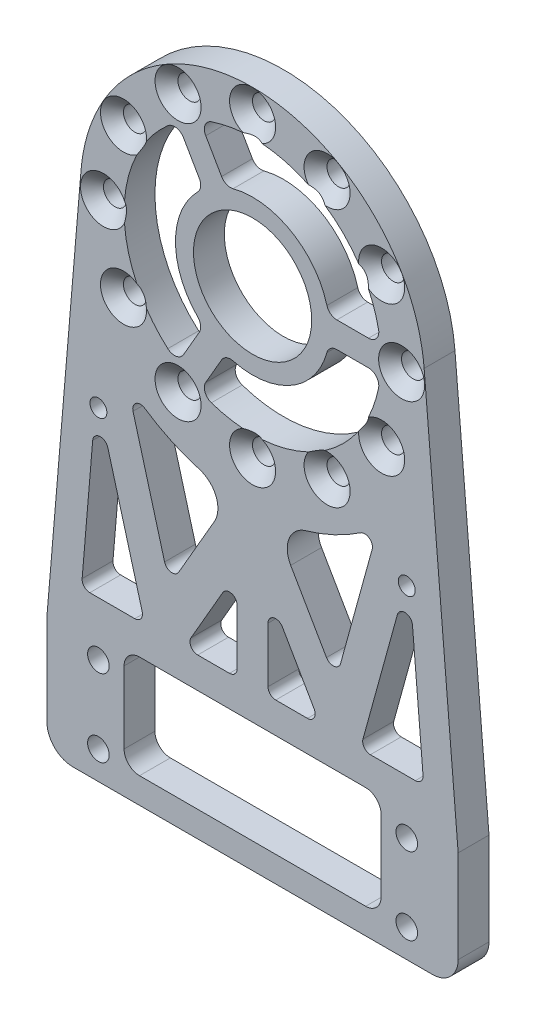
from build123d import *

# Parameters (mm, degrees)
SKETCH_1_R                   = 33.5
SKETCH_1_R_2                 = 25
SKETCH_1_W                   = 80
SKETCH_1_H                   = 20
SKETCH_1_R_3                 = 2.1
EXTRUDE_1_DEPTH              = 6
SKETCH_3_R                   = 2.05
CUT_EXTRUDE_1_DEPTH          = 7
EXTRUDE_2_DEPTH              = 6
FILLET_1_R                   = 2
SKETCH_5_W                   = 80
SKETCH_5_H                   = 3
EXTRUDE_3_DEPTH              = 6
FILLET_2_R                   = 5
SKETCH_6_W                   = 50
SKETCH_6_H                   = 20
CUT_EXTRUDE_2_DEPTH          = 10
FILLET_3_R                   = 3
FILLET_4_R                   = 1.5
FILLET_5_R                   = 5
HOLE_WIZARD_M4_2_D           = 4.5
HOLE_WIZARD_M4_2_CSINK_D     = 8.96
HOLE_WIZARD_M4_2_CSINK_ANGLE = 90
SKETCH_10_R                  = 1.65
CUT_EXTRUDE_3_DEPTH          = 7.0000001


with BuildPart() as part:
    # 草图1 → 凸台-拉伸1 (new body)
    with BuildSketch(Plane.XY):
        with Locations((0, 85.5)):
            Circle(SKETCH_1_R)
        with Locations((0, 85.5)):
            Circle(SKETCH_1_R_2, mode=Mode.SUBTRACT)
        with BuildLine():
            Line((-33.38100662, 88.32106311), (-40, 10))
            Line((-40, 10), (40, 10))
            Line((40, 10), (33.38100662, 88.32106311))
            ThreePointArc((33.38100662, 88.32106311), (33.470238435, 86.911785792), (33.5, 85.5))
            ThreePointArc((33.5, 85.5), (-1.411785792, 52.029761565), (-33.38100662, 88.32106311))
        make_face()
        Rectangle(SKETCH_1_W, SKETCH_1_H)
        with Locations((-30, 7.5)):
            Circle(SKETCH_1_R_3, mode=Mode.SUBTRACT)
        with Locations((30, 7.5)):
            Circle(SKETCH_1_R_3, mode=Mode.SUBTRACT)
        with Locations((30, -7.5)):
            Circle(SKETCH_1_R_3, mode=Mode.SUBTRACT)
        with Locations((-30, -7.5)):
            Circle(SKETCH_1_R_3, mode=Mode.SUBTRACT)
    extrude(amount=EXTRUDE_1_DEPTH)

    # 草图3 → 切除-拉伸1 (cut, through all)
    with BuildSketch(Plane.XY.offset(6)):
        with Locations((0, 114.5)):
            Circle(SKETCH_3_R)
        with Locations((14.5, 110.61473671)):
            Circle(SKETCH_3_R)
        with Locations((25.11473671, 100)):
            Circle(SKETCH_3_R)
        with Locations((29, 85.5)):
            Circle(SKETCH_3_R)
        with Locations((25.11473671, 71)):
            Circle(SKETCH_3_R)
        with Locations((14.5, 60.38526329)):
            Circle(SKETCH_3_R)
        with Locations((0, 56.5)):
            Circle(SKETCH_3_R)
        with Locations((-14.5, 60.38526329)):
            Circle(SKETCH_3_R)
        with Locations((-25.11473671, 71)):
            Circle(SKETCH_3_R)
        with Locations((-29, 85.5)):
            Circle(SKETCH_3_R)
        with Locations((-25.11473671, 100)):
            Circle(SKETCH_3_R)
        with Locations((-14.5, 110.61473671)):
            Circle(SKETCH_3_R)
    extrude(amount=-CUT_EXTRUDE_1_DEPTH, mode=Mode.SUBTRACT)


with BuildPart() as body_2:
    # 草图4 → 凸台-拉伸2 (new body)
    with BuildSketch(Plane.XY.offset(6)):
        with BuildLine():
            ThreePointArc((-10.272279454, 108.292109925), (-12.5, 107.150635095), (-14.602406473, 105.792109925))
            Line((-14.602406473, 105.792109925), (-9.560163238, 97.058688457))
            Line((-9.560163238, 97.058688457), (-7.77754959, 93.971111048))
            ThreePointArc((-7.77754959, 93.971111048), (-5.75, 95.459292144), (-3.447422571, 96.471111048))
            Line((-3.447422571, 96.471111048), (-5.230036219, 99.558688457))
            Line((-5.230036219, 99.558688457), (-10.272279454, 108.292109925))
        make_face()
        with BuildLine():
            ThreePointArc((25, 85.5), (24.968651828, 86.751569376), (24.874685928, 88))
            Line((24.874685928, 88), (14.790199458, 88))
            Line((14.790199458, 88), (11.22497216, 88))
            ThreePointArc((11.22497216, 88), (11.431036258, 86.757541283), (11.5, 85.5))
            ThreePointArc((11.5, 85.5), (11.431036258, 84.242458717), (11.22497216, 83))
            Line((11.22497216, 83), (14.790199458, 83))
            Line((14.790199458, 83), (24.874685928, 83))
            ThreePointArc((24.874685928, 83), (24.968651828, 84.248430624), (25, 85.5))
        make_face()
        with BuildLine():
            Line((-9.560163238, 73.941311543), (-14.602406473, 65.207890075))
            ThreePointArc((-14.602406473, 65.207890075), (-12.5, 63.849364905), (-10.272279454, 62.707890075))
            Line((-10.272279454, 62.707890075), (-5.230036219, 71.441311543))
            Line((-5.230036219, 71.441311543), (-3.447422571, 74.528888952))
            ThreePointArc((-3.447422571, 74.528888952), (-5.75, 75.540707856), (-7.77754959, 77.028888952))
            Line((-7.77754959, 77.028888952), (-9.560163238, 73.941311543))
        make_face()
        with BuildLine():
            Line((-7.77754959, 93.971111048), (-9.560163238, 97.058688457))
            ThreePointArc((-9.560163238, 97.058688457), (-15, 85.5), (-9.560163238, 73.941311543))
            Line((-9.560163238, 73.941311543), (-7.77754959, 77.028888952))
            ThreePointArc((-7.77754959, 77.028888952), (-11.5, 85.5), (-7.77754959, 93.971111048))
        make_face()
        with BuildLine():
            Line((-3.447422571, 74.528888952), (-5.230036219, 71.441311543))
            ThreePointArc((-5.230036219, 71.441311543), (7.5, 72.509618943), (14.790199458, 83))
            Line((14.790199458, 83), (11.22497216, 83))
            ThreePointArc((11.22497216, 83), (5.75, 75.540707856), (-3.447422571, 74.528888952))
        make_face()
        with BuildLine():
            ThreePointArc((14.790199458, 88), (7.5, 98.490381057), (-5.230036219, 99.558688457))
            Line((-5.230036219, 99.558688457), (-3.447422571, 96.471111048))
            ThreePointArc((-3.447422571, 96.471111048), (5.75, 95.459292144), (11.22497216, 88))
            Line((11.22497216, 88), (14.790199458, 88))
        make_face()
    extrude(amount=-EXTRUDE_2_DEPTH)

    # Combine 1: union part
    add(part.part)

    # 圆角1
    fillet_1_edges = [body_2.edges().sort_by_distance(p)[0] for p in [
        (-9.560163238, 73.941311543, 3),
        (-14.602406473, 65.207890075, 3),
        (-10.272279454, 62.707890075, 3),
        (-5.230036219, 71.441311543, 3),
        (14.790199458, 83, 3),
        (24.874685928, 83, 3),
        (24.874685928, 88, 3),
        (14.790199458, 88, 3),
        (-5.230036219, 99.558688457, 3),
        (-10.272279454, 108.292109925, 3),
        (-14.602406473, 105.792109925, 3),
        (-9.560163238, 97.058688457, 3),
    ]]
    fillet(fillet_1_edges, radius=FILLET_1_R)

    # 草图5 → 凸台-拉伸3 (add)
    with BuildSketch(Plane.XY.offset(6)):
        with Locations((0, -11.5)):
            Rectangle(SKETCH_5_W, SKETCH_5_H)
    extrude(amount=-EXTRUDE_3_DEPTH)

    # 圆角2
    fillet_2_edges = [body_2.edges().sort_by_distance(p)[0] for p in [
        (-40, -13, 3),
        (40, -13, 3),
    ]]
    fillet(fillet_2_edges, radius=FILLET_2_R)

    # 草图6 → 切除-拉伸2 (cut)
    with BuildSketch(Plane(origin=(0, 0, 0), x_dir=(-1, 0, 0), z_dir=(0, 0, -1))):
        Polygon((-13.279056191, 18), (-3, 18), (-3, 35.803847577), align=None)
        Polygon((3, 35.803847577), (3, 18), (13.279056191, 18), align=None)
        with Locations((0, 2)):
            Rectangle(SKETCH_6_W, SKETCH_6_H)
        Polygon((-33.302523575, 18), (-20.950767875, 18), (-30.401818232, 52.323395297), align=None)
        with BuildLine():
            Line((-16.167580049, 26.996929919), (-3.922674029, 48.205729281))
            ThreePointArc((-3.922674029, 48.205729281), (-14.860033774, 51.069934705), (-24.446601804, 57.063866996))
            Line((-24.446601804, 57.063866996), (-16.167580049, 26.996929919))
        make_face()
        with BuildLine():
            ThreePointArc((24.446601804, 57.063866996), (14.860033774, 51.069934705), (3.922674029, 48.205729281))
            Line((3.922674029, 48.205729281), (16.167580049, 26.996929919))
            Line((16.167580049, 26.996929919), (24.446601804, 57.063866996))
        make_face()
        Polygon((30.401818232, 52.323395297), (20.950767875, 18), (33.302523575, 18), align=None)
    extrude(amount=-CUT_EXTRUDE_2_DEPTH, mode=Mode.SUBTRACT)

    # 圆角3
    fillet_3_edges = [body_2.edges().sort_by_distance(p)[0] for p in [
        (-25, 12, 3),
        (-25, -8, 3),
        (25, -8, 3),
        (25, 12, 3),
    ]]
    fillet(fillet_3_edges, radius=FILLET_3_R)

    # 圆角4
    fillet_4_edges = [body_2.edges().sort_by_distance(p)[0] for p in [
        (-3, 35.803847577, 3),
        (-13.279056191, 18, 3),
        (-3, 18, 3),
        (3, 35.803847577, 3),
        (3, 18, 3),
        (13.279056191, 18, 3),
        (-24.446601804, 57.063866996, 3),
        (-16.167580049, 26.996929919, 3),
        (-20.950767875, 18, 3),
        (-30.401818232, 52.323395297, 3),
        (-33.302523575, 18, 3),
        (20.950767875, 18, 3),
        (33.302523575, 18, 3),
        (30.401818232, 52.323395297, 3),
        (24.446601804, 57.063866996, 3),
        (16.167580049, 26.996929919, 3),
    ]]
    fillet(fillet_4_edges, radius=FILLET_4_R)

    # 圆角5
    fillet_5_edges = [body_2.edges().sort_by_distance(p)[0] for p in [
        (-3.922674029, 48.205729281, 3),
        (3.922674029, 48.205729281, 3),
    ]]
    fillet(fillet_5_edges, radius=FILLET_5_R)

    # M4 六角凹锥坑螺钉的锥形沉头孔2 (through all)
    with Locations(Plane.XY.offset(6)):
        with Locations((-25.11473671, 100), (-14.5, 110.61473671), (0, 114.5), (14.5, 110.61473671), (25.11473671, 100), (29, 85.5), (25.11473671, 71), (14.5, 60.38526329), (0, 56.5), (-14.5, 60.38526329), (-25.11473671, 71), (-29, 85.5)):
            CounterSinkHole(HOLE_WIZARD_M4_2_D / 2, HOLE_WIZARD_M4_2_CSINK_D / 2, counter_sink_angle=HOLE_WIZARD_M4_2_CSINK_ANGLE)

    # 草图10 → 切除-拉伸3 (cut, through all)
    with BuildSketch(Plane(origin=(0, 0, 0), x_dir=(-1, 0, 0), z_dir=(0, 0, -1))):
        with Locations((30, 50)):
            Circle(SKETCH_10_R)
        with Locations((-30, 50)):
            Circle(SKETCH_10_R)
    extrude(amount=-CUT_EXTRUDE_3_DEPTH, mode=Mode.SUBTRACT)


solid = body_2.part
